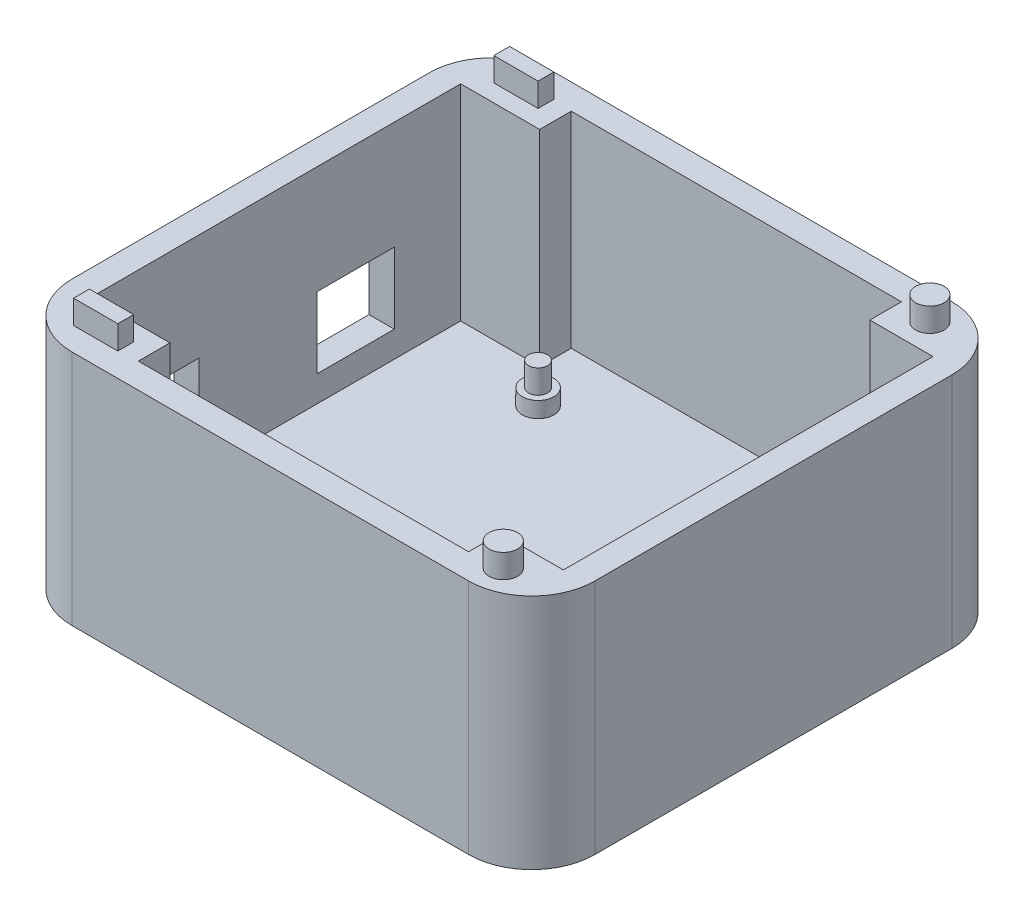
from build123d import *

# Parameters (mm, degrees)
SKETCH1_W            = 84.074
SKETCH1_H            = 77.724
BOSS_EXTRUDE1_DEPTH  = 5.08
SKETCH3_R            = 2.54
BOSS_EXTRUDE2_DEPTH  = 2.54
SKETCH19_W           = 12.7
SKETCH19_H           = 5.08
SKETCH19_W_2         = 10.16
BOSS_EXTRUDE7_DEPTH  = 33.02
FILLET2_R            = 10.16
SKETCH21_R           = 2.286
SKETCH21_W           = 7.112
SKETCH21_H           = 2.54
BOSS_EXTRUDE9_DEPTH  = 3.81
SKETCH22_W           = 12.446
SKETCH22_H           = 11.43
SKETCH22_W_2         = 9.779
SKETCH22_H_2         = 11.683309762
CUT_EXTRUDE10_DEPTH  = 5.08
SKETCH23_R           = 1.524
BOSS_EXTRUDE10_DEPTH = 3.81


with BuildPart() as part:
    # Sketch1 → Boss-Extrude1 (new body)
    with BuildSketch(Plane(origin=(0, 0, 0), x_dir=(1, 0, 0), z_dir=(0, 1, 0))):
        Rectangle(SKETCH1_W, SKETCH1_H)
    extrude(amount=BOSS_EXTRUDE1_DEPTH)

    # Sketch3 → Boss-Extrude2 (add)
    with BuildSketch(Plane(origin=(0, 5.08, 0), x_dir=(1, 0, 0), z_dir=(0, 1, 0))):
        with Locations((-19.939, 24.13)):
            Circle(SKETCH3_R)
        with Locations((-19.939, -24.13)):
            Circle(SKETCH3_R)
        with Locations((30.861, 8.89)):
            Circle(SKETCH3_R)
        with Locations((30.861, -19.05)):
            Circle(SKETCH3_R)
    extrude(amount=BOSS_EXTRUDE2_DEPTH)

    # Sketch19 → Boss-Extrude7 (add)
    with BuildSketch(Plane(origin=(0, 5.08, 0), x_dir=(1, 0, 0), z_dir=(0, 1, 0))):
        Polygon((-37.973, 34.798), (-42.037, 34.798), (-42.037, -34.798), (-37.973, -34.798), (-37.973, -29.718), (-37.973, 29.718), align=None)
        with Locations((-31.623, -32.258)):
            Rectangle(SKETCH19_W, SKETCH19_H)
        Polygon((42.037, -38.862), (42.037, 34.798), (37.973, 34.798), (37.973, 29.718), (37.973, -29.718), (37.973, -34.798), (37.973, -38.862), align=None)
        with Locations((32.893, 32.258)):
            Rectangle(SKETCH19_W_2, SKETCH19_H)
        Polygon((42.037, 38.862), (-42.037, 38.862), (-42.037, 34.798), (-37.973, 34.798), (-25.273, 34.798), (27.813, 34.798), (37.973, 34.798), (42.037, 34.798), align=None)
        with Locations((-31.623, 32.258)):
            Rectangle(SKETCH19_W, SKETCH19_H)
        Polygon((-37.973, -34.798), (-42.037, -34.798), (-42.037, -38.862), (37.973, -38.862), (37.973, -34.798), (27.813, -34.798), (-25.273, -34.798), align=None)
        with Locations((32.893, -32.258)):
            Rectangle(SKETCH19_W_2, SKETCH19_H)
    extrude(amount=BOSS_EXTRUDE7_DEPTH)

    # Fillet2
    fillet2_edges = [part.edges().sort_by_distance(p)[0] for p in [
        (42.037, 19.05, 38.862),
        (-42.037, 19.05, 38.862),
        (-42.037, 19.05, -38.862),
        (42.037, 19.05, -38.862),
    ]]
    fillet(fillet2_edges, radius=FILLET2_R)

    # Sketch21 → Boss-Extrude9 (add)
    with BuildSketch(Plane(origin=(0, 38.1, 0), x_dir=(1, 0, 0), z_dir=(0, 1, 0))):
        with Locations((32.893, 34.29)):
            Circle(SKETCH21_R)
        with Locations((-31.877, 33.782)):
            Rectangle(SKETCH21_W, SKETCH21_H)
    boss_extrude9 = extrude(amount=BOSS_EXTRUDE9_DEPTH)

    # Sketch22 → Cut-Extrude10 (cut)
    with BuildSketch(Plane.ZY.offset(42.037)):
        with Locations((-12.827, 14.986)):
            Rectangle(SKETCH22_W, SKETCH22_H)
        with Locations((17.2085, 15.112654881)):
            Rectangle(SKETCH22_W_2, SKETCH22_H_2)
    extrude(amount=-CUT_EXTRUDE10_DEPTH, mode=Mode.SUBTRACT)

    # Sketch23 → Boss-Extrude10 (add)
    with BuildSketch(Plane(origin=(0, 7.62, 0), x_dir=(1, 0, 0), z_dir=(0, 1, 0))):
        with Locations((-19.939, 24.13)):
            Circle(SKETCH23_R)
        with Locations((30.861, 8.89)):
            Circle(SKETCH23_R)
        with Locations((-19.939, -24.13)):
            Circle(SKETCH23_R)
        with Locations((30.861, -19.05)):
            Circle(SKETCH23_R)
    extrude(amount=BOSS_EXTRUDE10_DEPTH)

    # Mirror1: Boss-Extrude9 across plane
    add(boss_extrude9.mirror(Plane.XY))


solid = part.part
